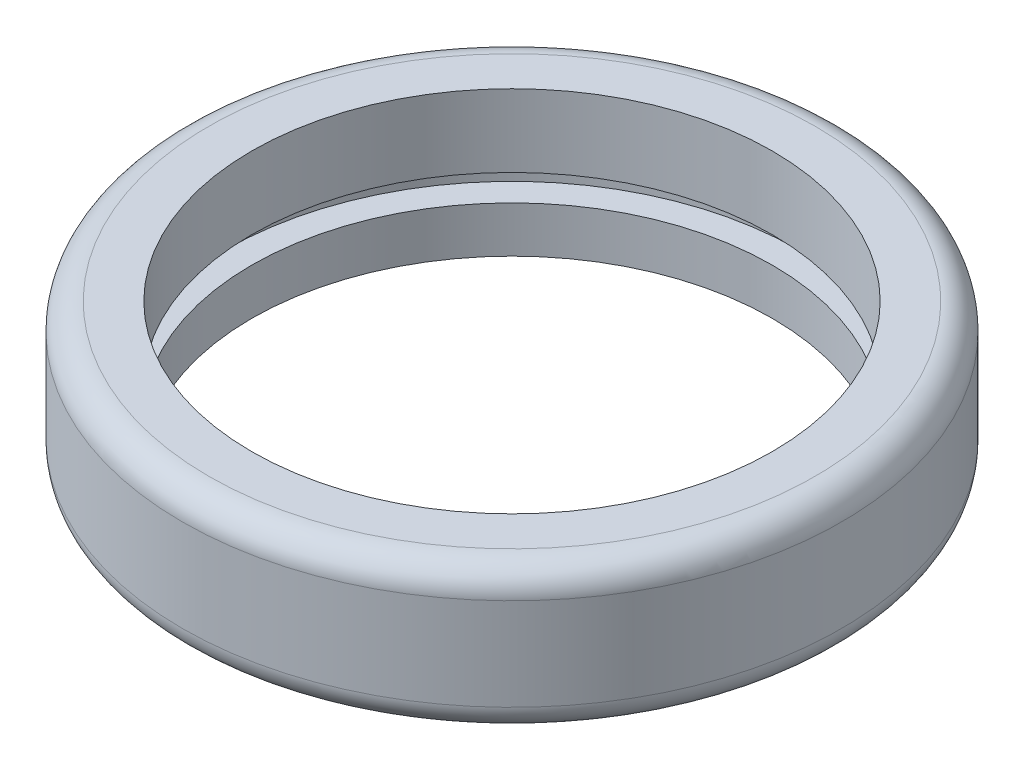
from build123d import *

# Parameters (mm, degrees)
FILLET1_R = 2


with BuildPart() as part:
    # Sketch1 → Revolve1 (revolve)
    with BuildSketch(Plane.XY):
        Polygon((19.75, -5.5), (19.75, -2), (21.75, -2), (21.75, 0), (19.75, 0), (19.75, 5.5), (25, 5.5), (25, -5.5), align=None)
    revolve(axis=Axis((0, 0, 0), (0, 1, 0)))

    # Fillet1
    fillet1_edges = [part.edges().sort_by_distance(p)[0] for p in [
        (-25, -5.5, 0),
        (-25, 5.5, 0),
    ]]
    fillet(fillet1_edges, radius=FILLET1_R)


solid = part.part
